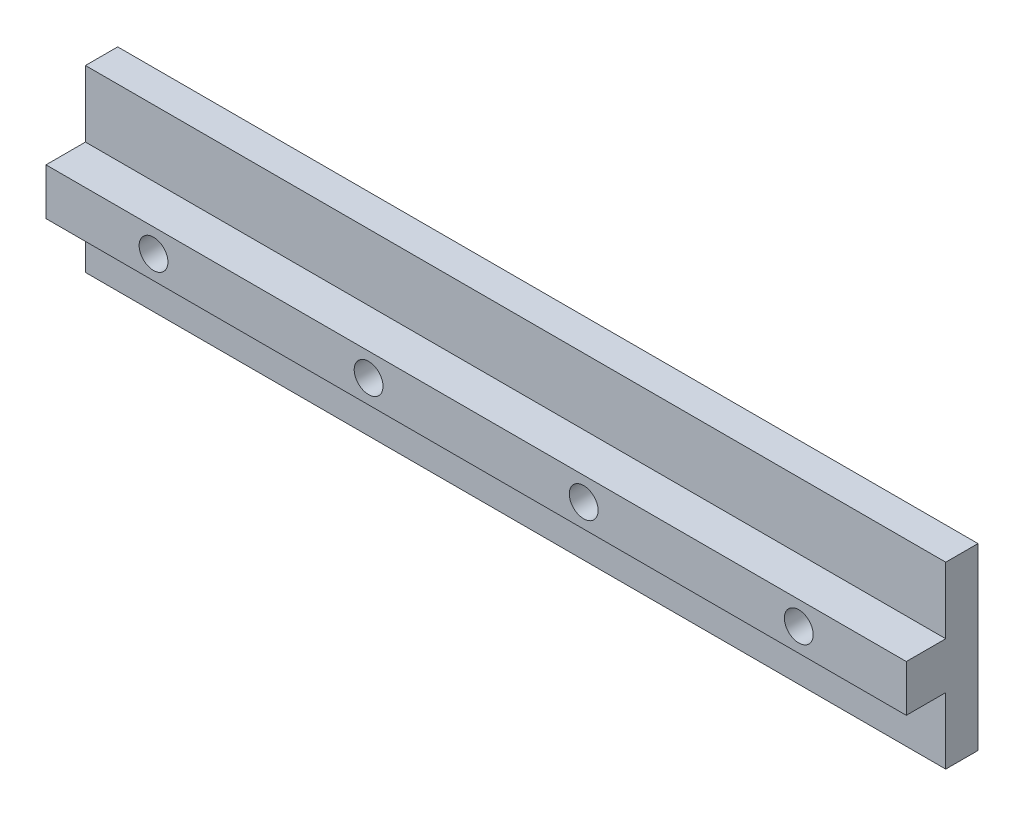
from build123d import *

# Parameters (mm, degrees)
SKETCH1_W                   = 152.4
SKETCH1_H                   = 31.75
BOSS_EXTRUDE1_DEPTH         = 12.7
SKETCH2_W                   = 152.4
SKETCH2_H                   = 11.7475
CUT_EXTRUDE1_DEPTH          = 6.985
F_1_4_20_TAPPED_HOLE1_D     = 5.1054
F_1_4_20_TAPPED_HOLE1_DEPTH = 12.7


with BuildPart() as part:
    # Sketch1 → Boss-Extrude1 (new body)
    with BuildSketch(Plane.XY):
        Rectangle(SKETCH1_W, SKETCH1_H)
    extrude(amount=BOSS_EXTRUDE1_DEPTH)

    # Sketch2 → Cut-Extrude1 (cut)
    with BuildSketch(Plane.XY.offset(12.7)):
        with Locations((0, 10.00125)):
            Rectangle(SKETCH2_W, SKETCH2_H)
        with Locations((0, -10.00125)):
            Rectangle(SKETCH2_W, SKETCH2_H)
    extrude(amount=-CUT_EXTRUDE1_DEPTH, mode=Mode.SUBTRACT)

    # 1/4-20 Tapped Hole1
    with Locations(Plane.XY.offset(12.7)):
        with Locations((-57.15, 0), (-19.05, 0), (19.05, 0), (57.15, 0)):
            Hole(F_1_4_20_TAPPED_HOLE1_D / 2, depth=F_1_4_20_TAPPED_HOLE1_DEPTH)


solid = part.part
